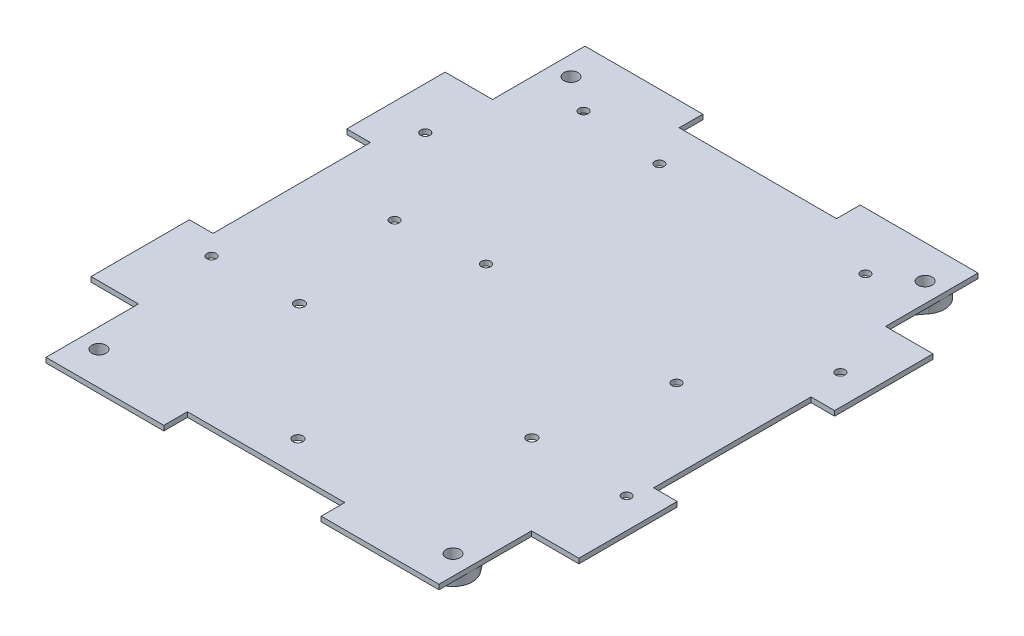
from build123d import *

# Parameters (mm, degrees)
SKETCH1_R           = 2.286
MAIN_BODY_DEPTH     = 1.5875
CUT_EXTRUDE1_REACH  = 119.348
SKETCH2_R           = 1.5
CUT_EXTRUDE2_REACH  = 119.348
SKETCH3_R           = 1.5
CUT_EXTRUDE3_REACH  = 119.348
SKETCH4_R           = 1.625
BOSS_EXTRUDE1_START = 3.175
SKETCH5_R           = 1.5
BOSS_EXTRUDE1_DEPTH = 3.175
CUT_EXTRUDE7_START  = -3.175
SKETCH14_R          = 1.5
CUT_EXTRUDE7_DEPTH  = 3.175
FILLET2_R           = 1.5875


with BuildPart() as part:
    # Sketch1 → Main Body (new body)
    with BuildSketch(Plane(origin=(0, 0, 0), x_dir=(1, 0, 0), z_dir=(0, 1, 0))):
        Polygon((-25.4, 79.375), (-25.4, 86.995), (-63.43142, 86.995), (-63.43142, 60.96), (-63.43142, 57.15), (-78.74, 57.15), (-78.74, 25.4), (-71.12, 25.4), (-71.12, -25.4), (-78.74, -25.4), (-78.74, -57.15), (-63.43142, -57.15), (-63.43142, -60.96), (-63.43142, -86.995), (-25.4, -86.995), (-25.4, -79.375), (25.4, -79.375), (25.4, -86.995), (63.43142, -86.995), (63.43142, -60.96), (63.43142, -57.15), (78.74, -57.15), (78.74, -25.4), (71.12, -25.4), (71.12, 25.4), (78.74, 25.4), (78.74, 57.15), (63.43142, 57.15), (63.43142, 60.96), (63.43142, 86.995), (25.4, 86.995), (25.4, 79.375), align=None)
        with Locations(Location((-57.15, -76.2, 0), (0, 0, 270))):
            Circle(SKETCH1_R, mode=Mode.SUBTRACT)
        with Locations(Location((57.15, -76.2, 0), (0, 0, 270))):
            Circle(SKETCH1_R, mode=Mode.SUBTRACT)
        with Locations(Location((-57.15, 76.2, 0), (0, 0, 270))):
            Circle(SKETCH1_R, mode=Mode.SUBTRACT)
        with Locations(Location((57.15, 76.2, 0), (0, 0, 270))):
            Circle(SKETCH1_R, mode=Mode.SUBTRACT)
    extrude(amount=MAIN_BODY_DEPTH)

    # Sketch2 → Cut-Extrude1 (cut, up to next)
    with BuildSketch(Plane.XZ, mode=Mode.PRIVATE) as cut_extrude1_sk1:
        with Locations(Location((69, -37, 0), (0, 0, 270))):
            Circle(SKETCH2_R)
    cut_extrude1_tool1 = extrude(cut_extrude1_sk1.sketch, amount=-CUT_EXTRUDE1_REACH, mode=Mode.PRIVATE) & part.part
    # Sketch2 → Cut-Extrude1 (cut, up to next)
    with BuildSketch(Plane.XZ, mode=Mode.PRIVATE) as cut_extrude1_sk2:
        with Locations(Location((-65, -37, 0), (0, 0, 270))):
            Circle(SKETCH2_R)
    cut_extrude1_tool2 = extrude(cut_extrude1_sk2.sketch, amount=-CUT_EXTRUDE1_REACH, mode=Mode.PRIVATE) & part.part
    # Sketch2 → Cut-Extrude1 (cut, up to next)
    with BuildSketch(Plane.XZ, mode=Mode.PRIVATE) as cut_extrude1_sk3:
        with Locations(Location((-65, 32, 0), (0, 0, 270))):
            Circle(SKETCH2_R)
    cut_extrude1_tool3 = extrude(cut_extrude1_sk3.sketch, amount=-CUT_EXTRUDE1_REACH, mode=Mode.PRIVATE) & part.part
    # Sketch2 → Cut-Extrude1 (cut, up to next)
    with BuildSketch(Plane.XZ, mode=Mode.PRIVATE) as cut_extrude1_sk4:
        with Locations(Location((69, 32, 0), (0, 0, 270))):
            Circle(SKETCH2_R)
    cut_extrude1_tool4 = extrude(cut_extrude1_sk4.sketch, amount=-CUT_EXTRUDE1_REACH, mode=Mode.PRIVATE) & part.part
    add(cut_extrude1_tool1.solids().sort_by_distance((69, 0, -37))[0], mode=Mode.SUBTRACT)
    add(cut_extrude1_tool2.solids().sort_by_distance((-65, 0, -37))[0], mode=Mode.SUBTRACT)
    add(cut_extrude1_tool3.solids().sort_by_distance((-65, 0, 32))[0], mode=Mode.SUBTRACT)
    add(cut_extrude1_tool4.solids().sort_by_distance((69, 0, 32))[0], mode=Mode.SUBTRACT)

    # Sketch3 → Cut-Extrude2 (cut, up to next)
    with BuildSketch(Plane(origin=(0, 1.5875, 0), x_dir=(1, 0, 0), z_dir=(0, 1, 0)), mode=Mode.PRIVATE) as cut_extrude2_sk1:
        with Locations(Location((-18.5, 66.1, 0), (0, 0, 270))):
            Circle(SKETCH3_R)
    cut_extrude2_tool1 = extrude(cut_extrude2_sk1.sketch, amount=-CUT_EXTRUDE2_REACH, mode=Mode.PRIVATE) & part.part
    # Sketch3 → Cut-Extrude2 (cut, up to next)
    with BuildSketch(Plane(origin=(0, 1.5875, 0), x_dir=(1, 0, 0), z_dir=(0, 1, 0)), mode=Mode.PRIVATE) as cut_extrude2_sk2:
        with Locations(Location((45.4999896, 68.6, 0), (0, 0, 270))):
            Circle(SKETCH3_R)
    cut_extrude2_tool2 = extrude(cut_extrude2_sk2.sketch, amount=-CUT_EXTRUDE2_REACH, mode=Mode.PRIVATE) & part.part
    # Sketch3 → Cut-Extrude2 (cut, up to next)
    with BuildSketch(Plane(origin=(0, 1.5875, 0), x_dir=(1, 0, 0), z_dir=(0, 1, 0)), mode=Mode.PRIVATE) as cut_extrude2_sk3:
        with Locations(Location((45.4999896, 7.6, 0), (0, 0, 270))):
            Circle(SKETCH3_R)
    cut_extrude2_tool3 = extrude(cut_extrude2_sk3.sketch, amount=-CUT_EXTRUDE2_REACH, mode=Mode.PRIVATE) & part.part
    # Sketch3 → Cut-Extrude2 (cut, up to next)
    with BuildSketch(Plane(origin=(0, 1.5875, 0), x_dir=(1, 0, 0), z_dir=(0, 1, 0)), mode=Mode.PRIVATE) as cut_extrude2_sk4:
        with Locations(Location((-18.5, 10.1, 0), (0, 0, 270))):
            Circle(SKETCH3_R)
    cut_extrude2_tool4 = extrude(cut_extrude2_sk4.sketch, amount=-CUT_EXTRUDE2_REACH, mode=Mode.PRIVATE) & part.part
    # Sketch3 → Cut-Extrude2 (cut, up to next)
    with BuildSketch(Plane(origin=(0, 1.5875, 0), x_dir=(1, 0, 0), z_dir=(0, 1, 0)), mode=Mode.PRIVATE) as cut_extrude2_sk5:
        with Locations(Location((-45.5, 68.6, 0), (0, 0, 270))):
            Circle(SKETCH3_R)
    cut_extrude2_tool5 = extrude(cut_extrude2_sk5.sketch, amount=-CUT_EXTRUDE2_REACH, mode=Mode.PRIVATE) & part.part
    # Sketch3 → Cut-Extrude2 (cut, up to next)
    with BuildSketch(Plane(origin=(0, 1.5875, 0), x_dir=(1, 0, 0), z_dir=(0, 1, 0)), mode=Mode.PRIVATE) as cut_extrude2_sk6:
        with Locations(Location((-45.5, 7.6, 0), (0, 0, 270))):
            Circle(SKETCH3_R)
    cut_extrude2_tool6 = extrude(cut_extrude2_sk6.sketch, amount=-CUT_EXTRUDE2_REACH, mode=Mode.PRIVATE) & part.part
    add(cut_extrude2_tool1.solids().sort_by_distance((-18.5, 1.5875, -66.1))[0], mode=Mode.SUBTRACT)
    add(cut_extrude2_tool2.solids().sort_by_distance((45.49999, 1.5875, -68.6))[0], mode=Mode.SUBTRACT)
    add(cut_extrude2_tool3.solids().sort_by_distance((45.49999, 1.5875, -7.6))[0], mode=Mode.SUBTRACT)
    add(cut_extrude2_tool4.solids().sort_by_distance((-18.5, 1.5875, -10.1))[0], mode=Mode.SUBTRACT)
    add(cut_extrude2_tool5.solids().sort_by_distance((-45.5, 1.5875, -68.6))[0], mode=Mode.SUBTRACT)
    add(cut_extrude2_tool6.solids().sort_by_distance((-45.5, 1.5875, -7.6))[0], mode=Mode.SUBTRACT)

    # Sketch4 → Cut-Extrude3 (cut, up to next)
    with BuildSketch(Plane(origin=(0, 1.5875, 0), x_dir=(1, 0, 0), z_dir=(0, 1, 0)), mode=Mode.PRIVATE) as cut_extrude3_sk1:
        with Locations(Location((-37.5, -31.1, 0), (0, 0, 270))):
            Circle(SKETCH4_R)
    cut_extrude3_tool1 = extrude(cut_extrude3_sk1.sketch, amount=-CUT_EXTRUDE3_REACH, mode=Mode.PRIVATE) & part.part
    # Sketch4 → Cut-Extrude3 (cut, up to next)
    with BuildSketch(Plane(origin=(0, 1.5875, 0), x_dir=(1, 0, 0), z_dir=(0, 1, 0)), mode=Mode.PRIVATE) as cut_extrude3_sk2:
        with Locations(Location((37.5, -31.1, 0), (0, 0, 270))):
            Circle(SKETCH4_R)
    cut_extrude3_tool2 = extrude(cut_extrude3_sk2.sketch, amount=-CUT_EXTRUDE3_REACH, mode=Mode.PRIVATE) & part.part
    # Sketch4 → Cut-Extrude3 (cut, up to next)
    with BuildSketch(Plane(origin=(0, 1.5875, 0), x_dir=(1, 0, 0), z_dir=(0, 1, 0)), mode=Mode.PRIVATE) as cut_extrude3_sk3:
        with Locations(Location((0, -69.1, 0), (0, 0, 270))):
            Circle(SKETCH4_R)
    cut_extrude3_tool3 = extrude(cut_extrude3_sk3.sketch, amount=-CUT_EXTRUDE3_REACH, mode=Mode.PRIVATE) & part.part
    add(cut_extrude3_tool1.solids().sort_by_distance((-37.5, 1.5875, 31.1))[0], mode=Mode.SUBTRACT)
    add(cut_extrude3_tool2.solids().sort_by_distance((37.5, 1.5875, 31.1))[0], mode=Mode.SUBTRACT)
    add(cut_extrude3_tool3.solids().sort_by_distance((0, 1.5875, 69.1))[0], mode=Mode.SUBTRACT)

    # Sketch5 → Boss-Extrude1 (add)
    # profile 1 of 17: a face of its own
    with BuildSketch(Plane.XZ.offset(BOSS_EXTRUDE1_START)):
        with BuildLine():
            Line((-52.124864, -79.968852), (0, -10.469033333))
            Line((0, -10.469033333), (52.124864, -79.968852))
            ThreePointArc((52.124864, -79.968852), (53.381148, -71.174864), (62.175136, -72.431148))
            Line((62.175136, -72.431148), (8.238277017, -0.515336023))
            Line((8.238277017, -0.515336023), (7.851775, 0))
            Line((7.851775, 0), (62.175136, 72.431148))
            ThreePointArc((62.175136, 72.431148), (53.381148, 71.174864), (52.124864, 79.968852))
            Line((52.124864, 79.968852), (0, 10.469033333))
            Line((0, 10.469033333), (-52.124864, 79.968852))
            ThreePointArc((-52.124864, 79.968852), (-51.190921758, 78.186359414), (-50.86858, 76.2))
            ThreePointArc((-50.86858, 76.2), (-55.163640586, 70.240921758), (-62.175136, 72.431148))
            Line((-62.175136, 72.431148), (-7.851775, 0))
            Line((-7.851775, 0), (-8.933393131, -1.442157508))
            Line((-8.933393131, -1.442157508), (-62.175136, -72.431148))
            ThreePointArc((-62.175136, -72.431148), (-55.163640586, -70.240921758), (-50.86858, -76.2))
            ThreePointArc((-50.86858, -76.2), (-51.190921758, -78.186359414), (-52.124864, -79.968852))
        make_face()
        with Locations(Location((-45.5, -68.6, 0), (0, 0, 90))):
            Circle(SKETCH5_R, mode=Mode.SUBTRACT)
        with Locations(Location((45.4999896, -68.6, 0), (0, 0, 90))):
            Circle(SKETCH5_R, mode=Mode.SUBTRACT)
    # profile 2 of 17: a face of its own
    with BuildSketch(Plane.XZ.offset(BOSS_EXTRUDE1_START)):
        with BuildLine():
            ThreePointArc((62.175136, -72.431148), (53.381148, -71.174864), (52.124864, -79.968852))
            Line((52.124864, -79.968852), (55.3212, -77.5716))
            ThreePointArc((55.3212, -77.5716), (55.7784, -74.3712), (58.9788, -74.8284))
            Line((58.9788, -74.8284), (62.175136, -72.431148))
        make_face()
    # profile 3 of 17: a face of its own
    with BuildSketch(Plane.XZ.offset(BOSS_EXTRUDE1_START)):
        with BuildLine():
            Line((55.3212, -77.5716), (52.124864, -79.968852))
            ThreePointArc((52.124864, -79.968852), (59.136359414, -82.159078242), (63.43142, -76.2))
            ThreePointArc((63.43142, -76.2), (63.109078242, -74.213640586), (62.175136, -72.431148))
            Line((62.175136, -72.431148), (58.9788, -74.8284))
            ThreePointArc((58.9788, -74.8284), (59.318690019, -75.477103327), (59.436, -76.2))
            ThreePointArc((59.436, -76.2), (57.872896673, -78.368690019), (55.3212, -77.5716))
        make_face()
    # profile 4 of 17: a face of its own
    with BuildSketch(Plane.XZ.offset(BOSS_EXTRUDE1_START)):
        with BuildLine():
            ThreePointArc((62.175136, -72.431148), (53.381148, -71.174864), (52.124864, -79.968852))
            Line((52.124864, -79.968852), (55.3212, -77.5716))
            ThreePointArc((55.3212, -77.5716), (55.7784, -74.3712), (58.9788, -74.8284))
            Line((58.9788, -74.8284), (62.175136, -72.431148))
        make_face()
    # profile 5 of 17: a face of its own
    with BuildSketch(Plane.XZ.offset(BOSS_EXTRUDE1_START)):
        with BuildLine():
            Line((55.3212, -77.5716), (52.124864, -79.968852))
            ThreePointArc((52.124864, -79.968852), (59.136359414, -82.159078242), (63.43142, -76.2))
            ThreePointArc((63.43142, -76.2), (63.109078242, -74.213640586), (62.175136, -72.431148))
            Line((62.175136, -72.431148), (58.9788, -74.8284))
            ThreePointArc((58.9788, -74.8284), (59.318690019, -75.477103327), (59.436, -76.2))
            ThreePointArc((59.436, -76.2), (57.872896673, -78.368690019), (55.3212, -77.5716))
        make_face()
    # profile 6 of 17: a face of its own
    with BuildSketch(Plane.XZ.offset(BOSS_EXTRUDE1_START)):
        with BuildLine():
            ThreePointArc((-63.43142, -76.2), (-59.136359414, -82.159078242), (-52.124864, -79.968852))
            Line((-52.124864, -79.968852), (-55.3212, -77.5716))
            ThreePointArc((-55.3212, -77.5716), (-58.5216, -78.0288), (-58.9788, -74.8284))
            Line((-58.9788, -74.8284), (-62.175136, -72.431148))
            ThreePointArc((-62.175136, -72.431148), (-63.109078242, -74.213640586), (-63.43142, -76.2))
        make_face()
    # profile 7 of 17: a face of its own
    with BuildSketch(Plane.XZ.offset(BOSS_EXTRUDE1_START)):
        with BuildLine():
            Line((-55.3212, -77.5716), (-52.124864, -79.968852))
            ThreePointArc((-52.124864, -79.968852), (-51.190921758, -78.186359414), (-50.86858, -76.2))
            ThreePointArc((-50.86858, -76.2), (-55.163640586, -70.240921758), (-62.175136, -72.431148))
            Line((-62.175136, -72.431148), (-58.9788, -74.8284))
            ThreePointArc((-58.9788, -74.8284), (-56.427103327, -74.031309981), (-54.864, -76.2))
            ThreePointArc((-54.864, -76.2), (-54.981309981, -76.922896673), (-55.3212, -77.5716))
        make_face()
    # profile 8 of 17: a face of its own
    with BuildSketch(Plane.XZ.offset(BOSS_EXTRUDE1_START)):
        with BuildLine():
            ThreePointArc((-63.43142, -76.2), (-59.136359414, -82.159078242), (-52.124864, -79.968852))
            Line((-52.124864, -79.968852), (-55.3212, -77.5716))
            ThreePointArc((-55.3212, -77.5716), (-58.5216, -78.0288), (-58.9788, -74.8284))
            Line((-58.9788, -74.8284), (-62.175136, -72.431148))
            ThreePointArc((-62.175136, -72.431148), (-63.109078242, -74.213640586), (-63.43142, -76.2))
        make_face()
    # profile 9 of 17: a face of its own
    with BuildSketch(Plane.XZ.offset(BOSS_EXTRUDE1_START)):
        with BuildLine():
            Line((-55.3212, -77.5716), (-52.124864, -79.968852))
            ThreePointArc((-52.124864, -79.968852), (-51.190921758, -78.186359414), (-50.86858, -76.2))
            ThreePointArc((-50.86858, -76.2), (-55.163640586, -70.240921758), (-62.175136, -72.431148))
            Line((-62.175136, -72.431148), (-58.9788, -74.8284))
            ThreePointArc((-58.9788, -74.8284), (-56.427103327, -74.031309981), (-54.864, -76.2))
            ThreePointArc((-54.864, -76.2), (-54.981309981, -76.922896673), (-55.3212, -77.5716))
        make_face()
    # profile 10 of 17: a face of its own
    with BuildSketch(Plane.XZ.offset(BOSS_EXTRUDE1_START)):
        with BuildLine():
            ThreePointArc((-63.43142, 76.2), (-63.109078242, 74.213640586), (-62.175136, 72.431148))
            Line((-62.175136, 72.431148), (-58.9788, 74.8284))
            ThreePointArc((-58.9788, 74.8284), (-58.5216, 78.0288), (-55.3212, 77.5716))
            Line((-55.3212, 77.5716), (-52.124864, 79.968852))
            ThreePointArc((-52.124864, 79.968852), (-59.136359414, 82.159078242), (-63.43142, 76.2))
        make_face()
    # profile 11 of 17: a face of its own
    with BuildSketch(Plane.XZ.offset(BOSS_EXTRUDE1_START)):
        with BuildLine():
            Line((-58.9788, 74.8284), (-62.175136, 72.431148))
            ThreePointArc((-62.175136, 72.431148), (-55.163640586, 70.240921758), (-50.86858, 76.2))
            ThreePointArc((-50.86858, 76.2), (-51.190921758, 78.186359414), (-52.124864, 79.968852))
            Line((-52.124864, 79.968852), (-55.3212, 77.5716))
            ThreePointArc((-55.3212, 77.5716), (-54.981309981, 76.922896673), (-54.864, 76.2))
            ThreePointArc((-54.864, 76.2), (-56.427103327, 74.031309981), (-58.9788, 74.8284))
        make_face()
    # profile 12 of 17: a face of its own
    with BuildSketch(Plane.XZ.offset(BOSS_EXTRUDE1_START)):
        with BuildLine():
            ThreePointArc((-63.43142, 76.2), (-63.109078242, 74.213640586), (-62.175136, 72.431148))
            Line((-62.175136, 72.431148), (-58.9788, 74.8284))
            ThreePointArc((-58.9788, 74.8284), (-58.5216, 78.0288), (-55.3212, 77.5716))
            Line((-55.3212, 77.5716), (-52.124864, 79.968852))
            ThreePointArc((-52.124864, 79.968852), (-59.136359414, 82.159078242), (-63.43142, 76.2))
        make_face()
    # profile 13 of 17: a face of its own
    with BuildSketch(Plane.XZ.offset(BOSS_EXTRUDE1_START)):
        with BuildLine():
            Line((-58.9788, 74.8284), (-62.175136, 72.431148))
            ThreePointArc((-62.175136, 72.431148), (-55.163640586, 70.240921758), (-50.86858, 76.2))
            ThreePointArc((-50.86858, 76.2), (-51.190921758, 78.186359414), (-52.124864, 79.968852))
            Line((-52.124864, 79.968852), (-55.3212, 77.5716))
            ThreePointArc((-55.3212, 77.5716), (-54.981309981, 76.922896673), (-54.864, 76.2))
            ThreePointArc((-54.864, 76.2), (-56.427103327, 74.031309981), (-58.9788, 74.8284))
        make_face()
    # profile 14 of 17: a face of its own
    with BuildSketch(Plane.XZ.offset(BOSS_EXTRUDE1_START)):
        with BuildLine():
            ThreePointArc((52.124864, 79.968852), (53.381148, 71.174864), (62.175136, 72.431148))
            Line((62.175136, 72.431148), (58.9788, 74.8284))
            ThreePointArc((58.9788, 74.8284), (55.7784, 74.3712), (55.3212, 77.5716))
            Line((55.3212, 77.5716), (52.124864, 79.968852))
        make_face()
    # profile 15 of 17: a face of its own
    with BuildSketch(Plane.XZ.offset(BOSS_EXTRUDE1_START)):
        with BuildLine():
            Line((58.9788, 74.8284), (62.175136, 72.431148))
            ThreePointArc((62.175136, 72.431148), (63.109078242, 74.213640586), (63.43142, 76.2))
            ThreePointArc((63.43142, 76.2), (59.136359414, 82.159078242), (52.124864, 79.968852))
            Line((52.124864, 79.968852), (55.3212, 77.5716))
            ThreePointArc((55.3212, 77.5716), (57.872896673, 78.368690019), (59.436, 76.2))
            ThreePointArc((59.436, 76.2), (59.318690019, 75.477103327), (58.9788, 74.8284))
        make_face()
    # profile 16 of 17: a face of its own
    with BuildSketch(Plane.XZ.offset(BOSS_EXTRUDE1_START)):
        with BuildLine():
            ThreePointArc((52.124864, 79.968852), (53.381148, 71.174864), (62.175136, 72.431148))
            Line((62.175136, 72.431148), (58.9788, 74.8284))
            ThreePointArc((58.9788, 74.8284), (55.7784, 74.3712), (55.3212, 77.5716))
            Line((55.3212, 77.5716), (52.124864, 79.968852))
        make_face()
    # profile 17 of 17: a face of its own
    with BuildSketch(Plane.XZ.offset(BOSS_EXTRUDE1_START)):
        with BuildLine():
            Line((58.9788, 74.8284), (62.175136, 72.431148))
            ThreePointArc((62.175136, 72.431148), (63.109078242, 74.213640586), (63.43142, 76.2))
            ThreePointArc((63.43142, 76.2), (59.136359414, 82.159078242), (52.124864, 79.968852))
            Line((52.124864, 79.968852), (55.3212, 77.5716))
            ThreePointArc((55.3212, 77.5716), (57.872896673, 78.368690019), (59.436, 76.2))
            ThreePointArc((59.436, 76.2), (59.318690019, 75.477103327), (58.9788, 74.8284))
        make_face()
    extrude(amount=-BOSS_EXTRUDE1_DEPTH)

    # Sketch14 → Cut-Extrude7 (cut)
    # profile 1 of 2: a face of its own
    with BuildSketch(Plane.XZ.offset(3.175).offset(CUT_EXTRUDE7_START)):
        with BuildLine():
            ThreePointArc((50.2624896, -68.6), (46.912270502, -64.051718027), (41.575090585, -65.902487447))
            Line((41.575090585, -65.902487447), (46.990629927, -73.123206569))
            ThreePointArc((46.990629927, -73.123206569), (49.358783505, -71.391257037), (50.2624896, -68.6))
        make_face()
        with Locations(Location((45.4999896, -68.6, 0), (0, 0, 90))):
            Circle(SKETCH14_R, mode=Mode.SUBTRACT)
    # profile 2 of 2: a face of its own
    with BuildSketch(Plane.XZ.offset(3.175).offset(CUT_EXTRUDE7_START)):
        with BuildLine():
            ThreePointArc((-41.575096012, -65.902494683), (-49.31, -65.7425), (-46.990631988, -73.123209317))
            Line((-46.990631988, -73.123209317), (-41.575096012, -65.902494683))
        make_face()
        with Locations(Location((-45.5, -68.6, 0), (0, 0, 90))):
            Circle(SKETCH14_R, mode=Mode.SUBTRACT)
    extrude(amount=CUT_EXTRUDE7_DEPTH, mode=Mode.SUBTRACT)

    # Fillet2
    fillet2_edges = [part.edges().sort_by_distance(p)[0] for p in [
        (41.575090585, -1.5875, -65.902487447),
        (46.990629927, -1.5875, -73.123206569),
        (-46.990631988, -1.5875, -73.123209317),
        (-41.575096012, -1.5875, -65.902494683),
    ]]
    fillet(fillet2_edges, radius=FILLET2_R)


solid = part.part
